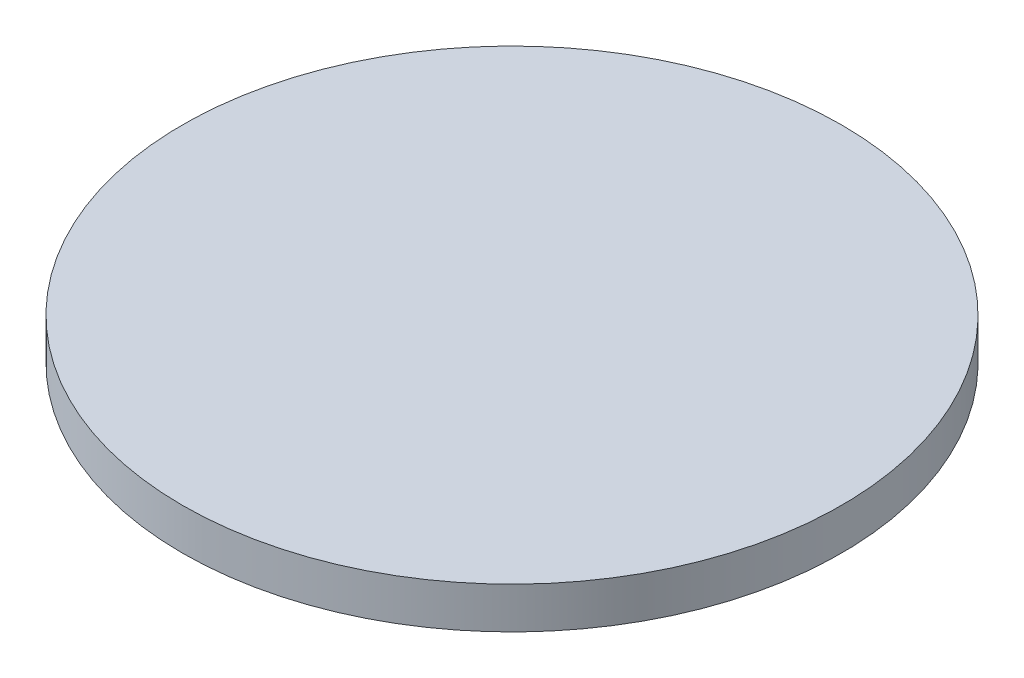
from build123d import *

# Parameters (mm, degrees)
SKETCH2_R           = 39.817970033
BOSS_EXTRUDE1_DEPTH = 5


with BuildPart() as part:
    # Sketch2 → Boss-Extrude1 (new body)
    with BuildSketch(Plane(origin=(0, 0, 0), x_dir=(1, 0, 0), z_dir=(0, 1, 0))):
        Circle(SKETCH2_R)
    extrude(amount=BOSS_EXTRUDE1_DEPTH)


solid = part.part
